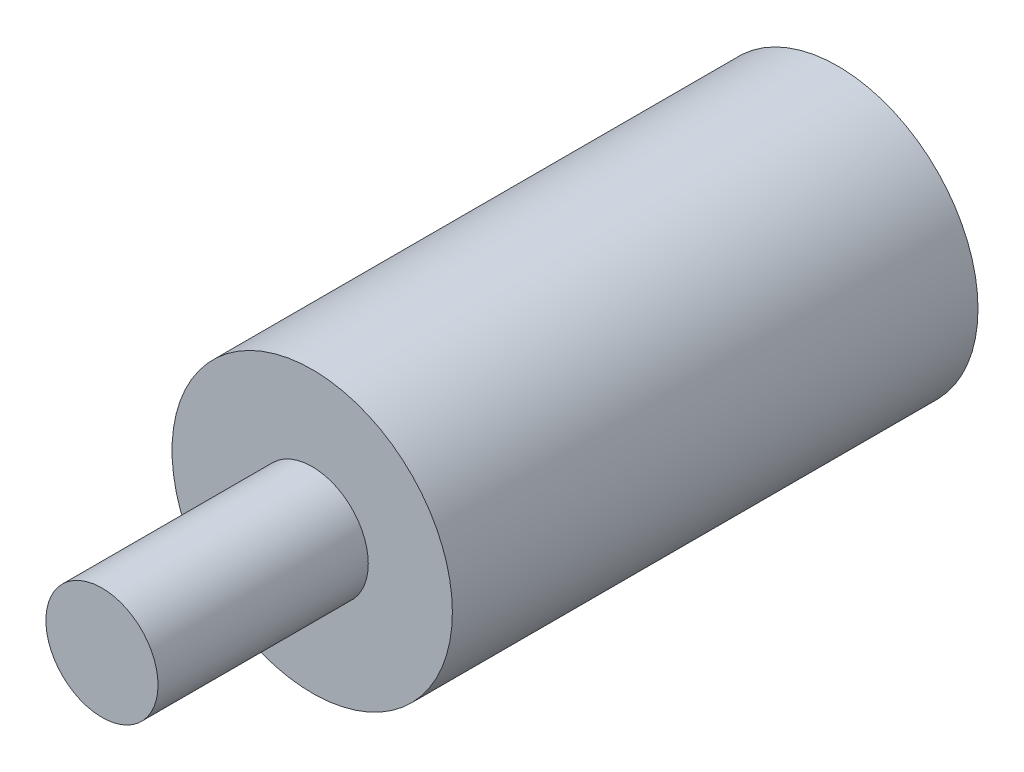
from build123d import *

# Parameters (mm, degrees)
SKETCH_2_R      = 100
EXTRUDE_1_DEPTH = 375
SKETCH_3_R      = 40
EXTRUDE_2_DEPTH = 150


with BuildPart() as part:
    # Эскиз2 → Бобышка-Вытянуть1 (new body)
    with BuildSketch(Plane.XY):
        Circle(SKETCH_2_R)
    extrude(amount=EXTRUDE_1_DEPTH)

    # Эскиз3 → Бобышка-Вытянуть2 (add)
    with BuildSketch(Plane.XY.offset(375)):
        Circle(SKETCH_3_R)
    extrude(amount=EXTRUDE_2_DEPTH)


solid = part.part
